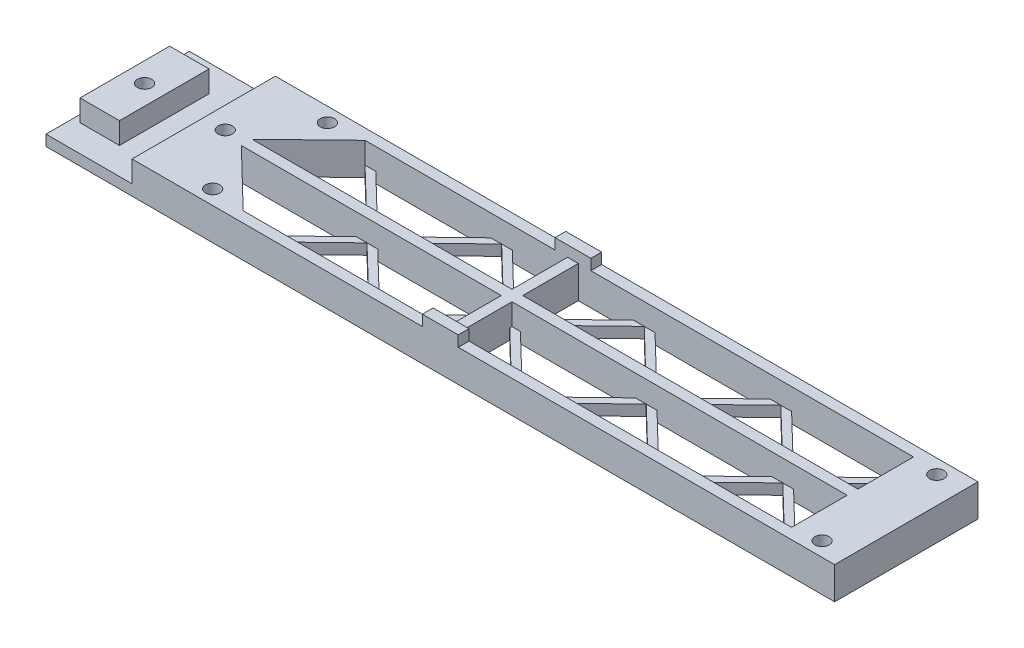
from build123d import *

# Parameters (mm, degrees)
BASESKETCH_W          = 220
BASESKETCH_H          = 40
BASE_DEPTH            = 3
HOLESSKETCH_R         = 2
HOLES_DEPTH           = 112.843640856
SUPPORTSKETCH_W       = 11
SUPPORTSKETCH_H       = 25
SUPPORTSKETCH_R       = 2
SUPPORTSKETCH_W_2     = 196
SUPPORTSKETCH_H_2     = 40
SUPPORTSKETCH_W_3     = 93.5
SUPPORTSKETCH_H_3     = 15.5
SUPPORT_DEPTH         = 6
CONNECTORSKETCH_W     = 10
CONNECTORSKETCH_H     = 3
CONNECTOR_DEPTH       = 3
WEIGHTREDUCTION_DEPTH = 113.165056947


with BuildPart() as part:
    # BaseSketch → Base (new body)
    with BuildSketch(Plane(origin=(0, 0, 0), x_dir=(1, 0, 0), z_dir=(0, 1, 0))):
        Rectangle(BASESKETCH_W, BASESKETCH_H)
    extrude(amount=BASE_DEPTH)

    # HolesSketch → Holes (cut, through all)
    with BuildSketch(Plane.XZ):
        with Locations(Location((-102.5, 0, 0), (0, 0, 270))):
            Circle(HOLESSKETCH_R)
        with Locations(Location((-80, 0, 0), (0, 0, 270))):
            Circle(HOLESSKETCH_R)
        with Locations(Location((-67.5, 16, 0), (0, 0, 270))):
            Circle(HOLESSKETCH_R)
        with Locations(Location((-67.5, -16, 0), (0, 0, 270))):
            Circle(HOLESSKETCH_R)
        with Locations(Location((102.5, -16, 0), (0, 0, 270))):
            Circle(HOLESSKETCH_R)
        with Locations(Location((102.5, 16, 0), (0, 0, 270))):
            Circle(HOLESSKETCH_R)
    extrude(amount=-HOLES_DEPTH, mode=Mode.SUBTRACT)

    # SupportSketch → Support (add)
    with BuildSketch(Plane(origin=(0, 3, 0), x_dir=(1, 0, 0), z_dir=(0, 1, 0))):
        with Locations((-102.5, 0)):
            Rectangle(SUPPORTSKETCH_W, SUPPORTSKETCH_H)
        with Locations(Location((-102.5, 0, 0), (0, 0, 90))):
            Circle(SUPPORTSKETCH_R, mode=Mode.SUBTRACT)
        with Locations((12, 0)):
            Rectangle(SUPPORTSKETCH_W_2, SUPPORTSKETCH_H_2)
        with Locations(Location((-67.5, -16, 0), (0, 0, 90))):
            Circle(SUPPORTSKETCH_R, mode=Mode.SUBTRACT)
        Polygon((-1.5, -1.5), (-1.5, -17), (-58, -17), (-74, -1.5), align=None, mode=Mode.SUBTRACT)
        with Locations(Location((102.5, -16, 0), (0, 0, 90))):
            Circle(SUPPORTSKETCH_R, mode=Mode.SUBTRACT)
        with Locations((48.25, -9.25)):
            Rectangle(SUPPORTSKETCH_W_3, SUPPORTSKETCH_H_3, mode=Mode.SUBTRACT)
        with Locations(Location((-80, 0, 0), (0, 0, 90))):
            Circle(SUPPORTSKETCH_R, mode=Mode.SUBTRACT)
        Polygon((-58, 17), (-1.5, 17), (-1.5, 1.5), (-74, 1.5), align=None, mode=Mode.SUBTRACT)
        with Locations(Location((-67.5, 16, 0), (0, 0, 90))):
            Circle(SUPPORTSKETCH_R, mode=Mode.SUBTRACT)
        with Locations((48.25, 9.25)):
            Rectangle(SUPPORTSKETCH_W_3, SUPPORTSKETCH_H_3, mode=Mode.SUBTRACT)
        with Locations(Location((102.5, 16, 0), (0, 0, 90))):
            Circle(SUPPORTSKETCH_R, mode=Mode.SUBTRACT)
    extrude(amount=SUPPORT_DEPTH)

    # ConnectorSketch → Connector (add)
    with BuildSketch(Plane(origin=(0, 9, 0), x_dir=(1, 0, 0), z_dir=(0, 1, 0))):
        with Locations((0, -18.5)):
            Rectangle(CONNECTORSKETCH_W, CONNECTORSKETCH_H)
        with Locations((0, 18.5)):
            Rectangle(CONNECTORSKETCH_W, CONNECTORSKETCH_H)
    extrude(amount=CONNECTOR_DEPTH)

    # WeightReductionSketch → WeightReduction (cut, symmetric)
    with BuildSketch(Plane(origin=(0, 9, 0), x_dir=(1, 0, 0), z_dir=(0, 1, 0))):
        Polygon((-74, 1.5), (-58, 17), (-41.949280136, 1.5), align=None)
        Polygon((-55, 17), (-38.949280136, 1.5), (-22.898560272, 17), align=None)
        Polygon((-19.898560272, 17), (-35.949280136, 1.5), (-3.847840409, 1.5), align=None)
        Polygon((-16.898560272, 17), (-1.5, 2.129783197), (-1.5, 17), align=None)
        Polygon((1.5, 2.129783197), (16.898560272, 17), (1.5, 17), align=None)
        Polygon((3.847840409, 1.5), (19.898560272, 17), (35.949280136, 1.5), align=None)
        Polygon((38.949280136, 1.5), (22.898560272, 17), (55, 17), align=None)
        Polygon((41.949280136, 1.5), (58, 17), (74.050719864, 1.5), align=None)
        Polygon((77.050719864, 1.5), (61, 17), (93.101439728, 17), align=None)
        Polygon((95, 15.936352019), (80.050719864, 1.5), (95, 1.5), align=None)
    weightreduction = extrude(amount=WEIGHTREDUCTION_DEPTH, both=True, mode=Mode.SUBTRACT)

    # WeightReductionMirror: WeightReduction across plane
    add(weightreduction.mirror(Plane.XY), mode=Mode.SUBTRACT)


solid = part.part
